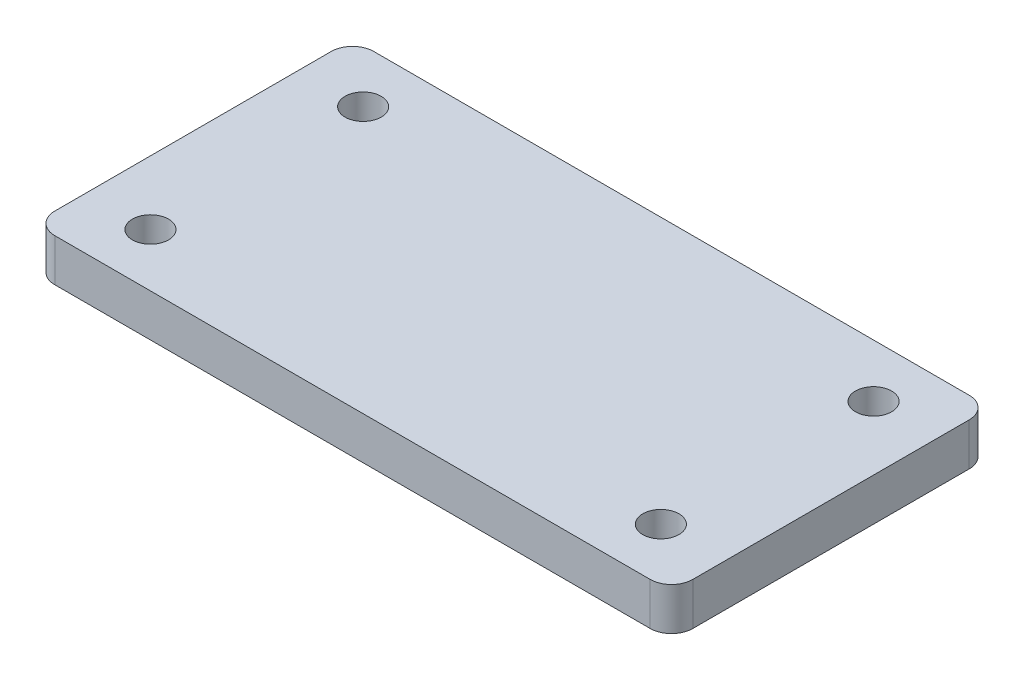
from build123d import *

# Parameters (mm, degrees)
SALIENTE_EXTRUIR2_DEPTH             = 20
DI_METRO_DE_TALADRO_17_0_17_1_D     = 17
DI_METRO_DE_TALADRO_17_0_17_1_DEPTH = 20


with BuildPart() as part:
    # Croquis1 → Saliente-Extruir2 (new body)
    with BuildSketch(Plane(origin=(0, 0, 0), x_dir=(1, 0, 0), z_dir=(0, 1, 0))):
        with BuildLine():
            Line((140, 75), (-140, 75))
            ThreePointArc((-140, 75), (-147.071067812, 72.071067812), (-150, 65))
            Line((-150, 65), (-150, -65))
            ThreePointArc((-150, -65), (-147.071067812, -72.071067812), (-140, -75))
            Line((-140, -75), (140, -75))
            ThreePointArc((140, -75), (147.071067812, -72.071067812), (150, -65))
            Line((150, -65), (150, 65))
            ThreePointArc((150, 65), (147.071067812, 72.071067812), (140, 75))
        make_face()
    extrude(amount=SALIENTE_EXTRUIR2_DEPTH)

    # Diámetro de taladro Ø17.0 (17)1
    with Locations(Plane(origin=(-120, 20, -50), x_dir=(0, 0, 1), z_dir=(0, 1, 0))):
        with Locations((0, 0), (100, 0), (100, 240), (0, 240)):
            Hole(DI_METRO_DE_TALADRO_17_0_17_1_D / 2, depth=DI_METRO_DE_TALADRO_17_0_17_1_DEPTH)


solid = part.part
